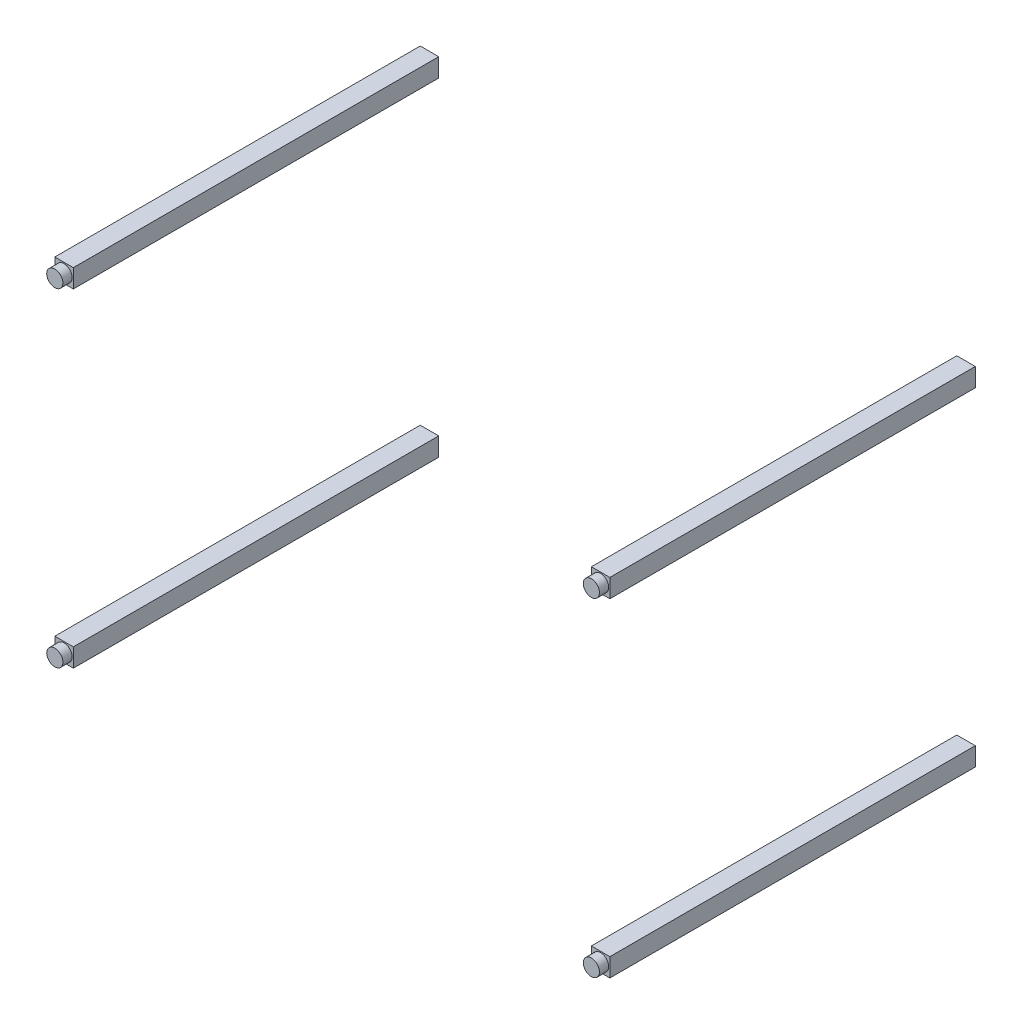
from build123d import *

# Parameters (mm, degrees)
SKETCH2_W             = 40
SKETCH2_H             = 40
BOSS_EXTRUDE1_DEPTH   = 790
BOSS_EXTRUDE1_2_DEPTH = 790
BOSS_EXTRUDE1_3_DEPTH = 790
BOSS_EXTRUDE1_4_DEPTH = 790
SKETCH3_R             = 17.5
BOSS_EXTRUDE2_DEPTH   = 20


with BuildPart() as part:
    # Sketch2 → Boss-Extrude1 (new body)
    with BuildSketch(Plane.XY.offset(39)):
        with Locations((-580, 355)):
            Rectangle(SKETCH2_W, SKETCH2_H)
    extrude(amount=BOSS_EXTRUDE1_DEPTH)



with BuildPart() as body_2:
    # Sketch2 → Boss-Extrude1 2 (new body)
    with BuildSketch(Plane.XY.offset(39)):
        with Locations((580, 355)):
            Rectangle(SKETCH2_W, SKETCH2_H)
    extrude(amount=BOSS_EXTRUDE1_2_DEPTH)


with BuildPart() as body_3:
    # Sketch2 → Boss-Extrude1 3 (new body)
    with BuildSketch(Plane.XY.offset(39)):
        with Locations((580, -355)):
            Rectangle(SKETCH2_W, SKETCH2_H)
    extrude(amount=BOSS_EXTRUDE1_3_DEPTH)


with BuildPart() as body_4:
    # Sketch2 → Boss-Extrude1 4 (new body)
    with BuildSketch(Plane.XY.offset(39)):
        with Locations((-580, -355)):
            Rectangle(SKETCH2_W, SKETCH2_H)
    extrude(amount=BOSS_EXTRUDE1_4_DEPTH)


with BuildPart() as part_1:
    add(part.part)

    add(body_2.part)  # Boss-Extrude2 merges body 2

    add(body_3.part)  # Boss-Extrude2 merges body 3

    add(body_4.part)  # Boss-Extrude2 merges body 4
    # Sketch3 → Boss-Extrude2 (add)
    with BuildSketch(Plane.XY.offset(829)):
        with Locations((-580, 355)):
            Circle(SKETCH3_R)
        with Locations((580, 355)):
            Circle(SKETCH3_R)
        with Locations((-580, -355)):
            Circle(SKETCH3_R)
        with Locations((580, -355)):
            Circle(SKETCH3_R)
    extrude(amount=BOSS_EXTRUDE2_DEPTH)


solid = part_1.part
